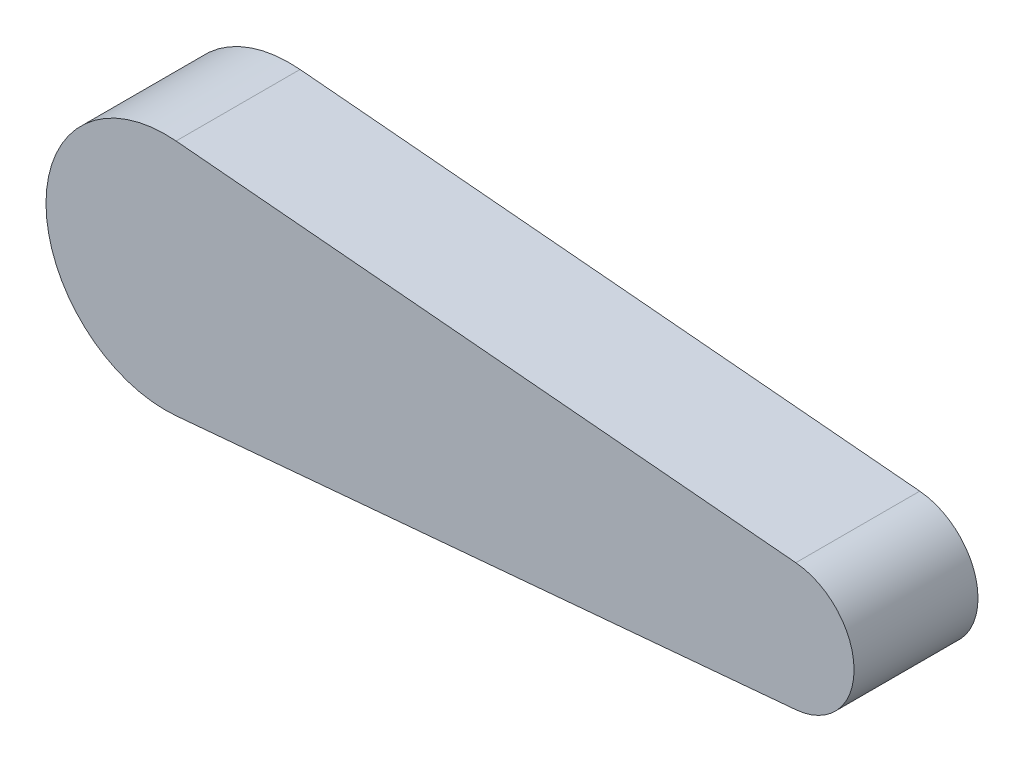
from build123d import *

# Parameters (mm, degrees)
BOSS_EXTRU_1_DEPTH = 10
SKETCH1_R          = 3.95
CUT_EXTRUDE1_DEPTH = 8


with BuildPart() as part:
    # Esquisse1 → Boss.-Extru.1 (new body)
    with BuildSketch(Plane.XY):
        with BuildLine():
            Line((10.495334687, 9.6), (60.495334687, 5.135702408))
            ThreePointArc((60.495334687, 5.135702408), (65.192921242, 0), (60.495334687, -5.135702408))
            Line((60.495334687, -5.135702408), (10.495334687, -9.6))
            ThreePointArc((10.495334687, -9.6), (0, 0), (10.495334687, 9.6))
        make_face()
    extrude(amount=BOSS_EXTRU_1_DEPTH)

    # Sketch1 → Cut-Extrude1 (cut)
    with BuildSketch(Plane(origin=(0, 0, 0), x_dir=(-1, 0, 0), z_dir=(0, 0, -1))):
        with Locations((-10.495334687, 0)):
            Circle(SKETCH1_R)
    extrude(amount=-CUT_EXTRUDE1_DEPTH, mode=Mode.SUBTRACT)


solid = part.part
